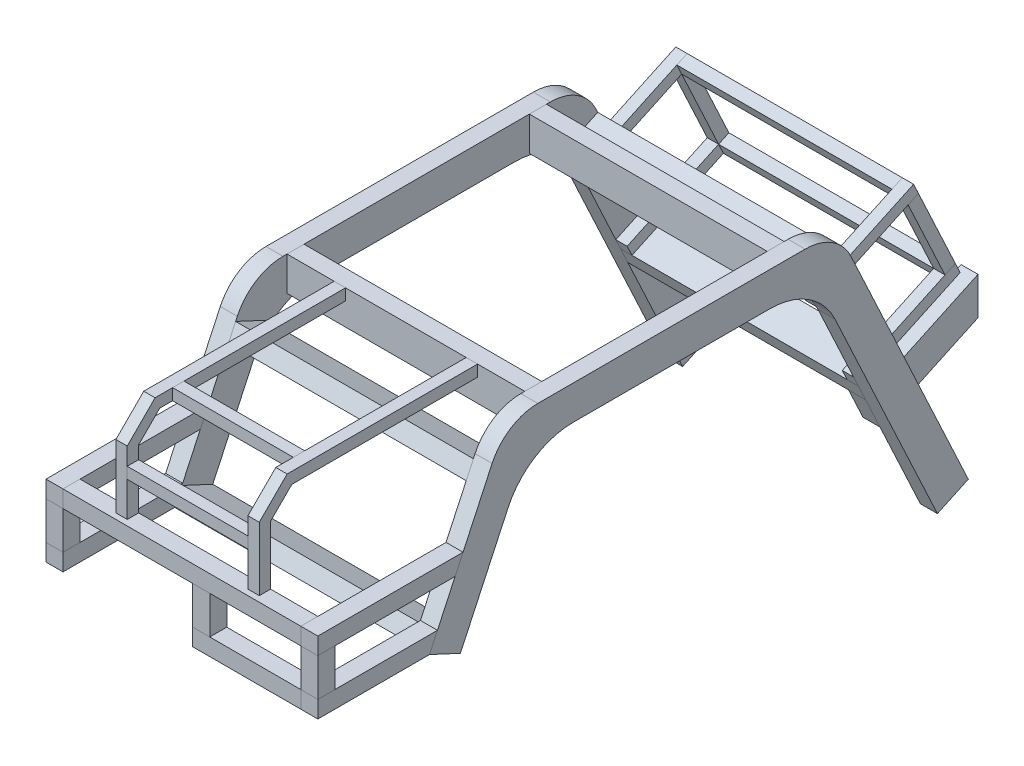
from build123d import *

# Parameters (mm, degrees)
BOSS_EXTRUDE1_START   = 239.55
BOSS_EXTRUDE1_DEPTH   = 30
BOSS_EXTRUDE2_DEPTH   = 30
BOSS_EXTRUDE2_2_DEPTH = 30
SKETCH12_W            = 29.999880001
SKETCH12_H            = 66.675
BOSS_EXTRUDE11_DEPTH  = 30
SKETCH3_W             = 30
SKETCH3_H             = 60
BOSS_EXTRUDE3_DEPTH   = 419.1
BOSS_EXTRUDE3_2_DEPTH = 419.1
BOSS_EXTRUDE3_3_DEPTH = 419.1
SKETCH3_W_2           = 29.999880001
SKETCH3_H_2           = 29.99988
BOSS_EXTRUDE3_4_DEPTH = 419.1
SKETCH3_H_3           = 29.999880001
BOSS_EXTRUDE3_5_DEPTH = 419.1
BOSS_EXTRUDE3_6_DEPTH = 419.1
BOSS_EXTRUDE3_7_DEPTH = 419.1
BOSS_EXTRUDE3_8_DEPTH = 419.1
BOSS_EXTRUDE4_DEPTH   = 30
BOSS_EXTRUDE5_DEPTH   = 30
BOSS_EXTRUDE5_2_DEPTH = 30
SKETCH13_W            = 29.999880001
SKETCH13_H            = 66.675
BOSS_EXTRUDE12_DEPTH  = 30
BOSS_EXTRUDE6_DEPTH   = 20
BOSS_EXTRUDE6_2_DEPTH = 20
BOSS_EXTRUDE13_DEPTH  = 20
BOSS_EXTRUDE7_DEPTH   = 379.1
BOSS_EXTRUDE7_2_DEPTH = 379.1
BOSS_EXTRUDE8_DEPTH   = 20
SKETCH9_W             = 20
SKETCH9_H             = 20
BOSS_EXTRUDE9_DEPTH   = 212.72
BOSS_EXTRUDE9_2_DEPTH = 212.72
SKETCH10_W            = 30
SKETCH10_H            = 66.675
BOSS_EXTRUDE10_DEPTH  = 30
SKETCH11_W            = 228.60006
SKETCH11_H            = 29.999880001
CUT_EXTRUDE1_DEPTH    = 29.99988
BOSS_EXTRUDE14_DEPTH  = 30
FILLET1_R             = 88.9
FILLET2_R             = 88.9
FILLET3_R             = 127
FILLET4_R             = 127


with BuildPart() as part:
    # Sketch1 → Boss-Extrude1 (new body)
    with BuildSketch(Plane(origin=(0, 0, 0), x_dir=(0, 0, -1), z_dir=(1, 0, 0)).offset(BOSS_EXTRUDE1_START)):
        Polygon((254, -30), (-254, -30), (-372.07954233, -283.222395698), (-426.458009553, -257.865299994), (-292.224215648, 30), (292.224215648, 30), (523.068544186, -465.04726011), (468.690076964, -490.404355815), align=None)
    extrude(amount=-BOSS_EXTRUDE1_DEPTH)

    # Fillet1
    fillet1_edges = [part.edges().sort_by_distance(p)[0] for p in [
        (224.55, 30, 292.224215648),
        (224.55, 30, -292.224215648),
    ]]
    fillet(fillet1_edges, radius=FILLET1_R)

    # Fillet3
    fillet3_edges = [part.edges().sort_by_distance(p)[0] for p in [
        (224.55, -30, -254),
        (224.55, -30, 254),
    ]]
    fillet(fillet3_edges, radius=FILLET3_R)


with BuildPart() as body_2:
    # Sketch2 → Boss-Extrude2 (new body)
    with BuildSketch(Plane(origin=(239.55, 0, 0), x_dir=(0, 0, -1), z_dir=(1, 0, 0))):
        Polygon((-381.377772657, -161.190419993), (-623.308009553, -161.190419993), (-623.308009553, -131.190539993), (-367.388598869, -131.190539993), align=None)
    extrude(amount=-BOSS_EXTRUDE2_DEPTH)


with BuildPart() as body_3:
    # Sketch2 → Boss-Extrude2 2 (new body)
    with BuildSketch(Plane(origin=(239.55, 0, 0), x_dir=(0, 0, -1), z_dir=(1, 0, 0))):
        Polygon((-412.468835765, -227.865419993), (-623.308009553, -227.865419993), (-623.308009553, -257.865299994), (-426.458009553, -257.865299994), align=None)
    extrude(amount=-BOSS_EXTRUDE2_2_DEPTH)


with BuildPart() as body_4:
    # Sketch12 → Boss-Extrude11 (new body)
    with BuildSketch(Plane(origin=(239.55, 0, 0), x_dir=(0, 0, -1), z_dir=(1, 0, 0))):
        with Locations((-608.308069553, -194.527919993)):
            Rectangle(SKETCH12_W, SKETCH12_H)
    extrude(amount=-BOSS_EXTRUDE11_DEPTH)


with BuildPart() as body_5:
    # Sketch3 → Boss-Extrude3 (new body)
    with BuildSketch(Plane.ZY.offset(-209.55)):
        with Locations((213.6, 0)):
            Rectangle(SKETCH3_W, SKETCH3_H)
    extrude(amount=BOSS_EXTRUDE3_DEPTH)


with BuildPart() as body_6:
    # Sketch3 → Boss-Extrude3 2 (new body)
    with BuildSketch(Plane.ZY.offset(-209.55)):
        Polygon((264.734503848, -53.020217791), (319.11297107, -27.663122086), (331.791518923, -54.852355697), (277.4130517, -80.209451402), align=None)
    extrude(amount=BOSS_EXTRUDE3_2_DEPTH)


with BuildPart() as body_7:
    # Sketch3 → Boss-Extrude3 3 (new body)
    with BuildSketch(Plane.ZY.offset(-209.55)):
        Polygon((372.07954233, -283.222395698), (426.458009553, -257.865299994), (413.7794617, -230.676066382), (359.400994478, -256.033162087), align=None)
    extrude(amount=BOSS_EXTRUDE3_3_DEPTH)


with BuildPart() as body_8:
    # Sketch3 → Boss-Extrude3 4 (new body)
    with BuildSketch(Plane.ZY.offset(-209.55)):
        with Locations((608.308069553, -146.190479993)):
            Rectangle(SKETCH3_W_2, SKETCH3_H_2)
    extrude(amount=BOSS_EXTRUDE3_4_DEPTH)


with BuildPart() as body_9:
    # Sketch3 → Boss-Extrude3 5 (new body)
    with BuildSketch(Plane.ZY.offset(-209.55)):
        with Locations((608.308069553, -242.865359994)):
            Rectangle(SKETCH3_W_2, SKETCH3_H_3)
    extrude(amount=BOSS_EXTRUDE3_5_DEPTH)

    # Sketch11 → Cut-Extrude1 (cut)
    with BuildSketch(Plane.XY.offset(623.308009553)):
        with Locations((-95.24997, -242.865359994)):
            Rectangle(SKETCH11_W, SKETCH11_H)
    extrude(amount=-CUT_EXTRUDE1_DEPTH, mode=Mode.SUBTRACT)


with BuildPart() as body_10:
    # Sketch3 → Boss-Extrude3 6 (new body)
    with BuildSketch(Plane.ZY.offset(-209.55)):
        Polygon((-359.400994478, -256.033162087), (-372.07954233, -283.222395698), (-426.458009553, -257.865299994), (-413.7794617, -230.676066382), align=None)
    extrude(amount=BOSS_EXTRUDE3_6_DEPTH)


with BuildPart() as body_11:
    # Sketch3 → Boss-Extrude3 7 (new body)
    with BuildSketch(Plane.ZY.offset(-209.55)):
        with Locations((-213.6, 0)):
            Rectangle(SKETCH3_W, SKETCH3_H)
    extrude(amount=BOSS_EXTRUDE3_7_DEPTH)


with BuildPart() as body_12:
    # Sketch3 → Boss-Extrude3 8 (new body)
    with BuildSketch(Plane.ZY.offset(-209.55)):
        Polygon((-331.791518923, -54.852355697), (-319.11297107, -27.663122086), (-264.734503848, -53.020217791), (-277.4130517, -80.209451402), align=None)
    extrude(amount=BOSS_EXTRUDE3_8_DEPTH)


with BuildPart() as body_13:
    # Sketch4 → Boss-Extrude4 (new body)
    with BuildSketch(Plane.ZY.offset(209.55)):
        Polygon((372.07954233, -283.222395698), (426.458009553, -257.865299994), (292.224215648, 30), (-292.224215648, 30), (-523.068544186, -465.04726011), (-468.690076964, -490.404355815), (-254, -30), (254, -30), align=None)
    extrude(amount=BOSS_EXTRUDE4_DEPTH)

    # Fillet2
    fillet2_edges = [body_13.edges().sort_by_distance(p)[0] for p in [
        (-224.55, 30, -292.224215648),
        (-224.55, 30, 292.224215648),
    ]]
    fillet(fillet2_edges, radius=FILLET2_R)

    # Fillet4
    fillet4_edges = [body_13.edges().sort_by_distance(p)[0] for p in [
        (-224.55, -30, 254),
        (-224.55, -30, -254),
    ]]
    fillet(fillet4_edges, radius=FILLET4_R)


with BuildPart() as body_14:
    # Sketch5 → Boss-Extrude5 (new body)
    with BuildSketch(Plane.ZY.offset(239.55)):
        Polygon((623.308009553, -227.865419993), (412.468835765, -227.865419993), (426.458009553, -257.865299994), (623.308009553, -257.865299994), align=None)
    extrude(amount=-BOSS_EXTRUDE5_DEPTH)


with BuildPart() as body_15:
    # Sketch5 → Boss-Extrude5 2 (new body)
    with BuildSketch(Plane.ZY.offset(239.55)):
        Polygon((381.377772657, -161.190419993), (623.308009553, -161.190419993), (623.308009553, -131.190539993), (367.388598869, -131.190539993), align=None)
    extrude(amount=-BOSS_EXTRUDE5_2_DEPTH)


with BuildPart() as body_16:
    # Sketch13 → Boss-Extrude12 (new body)
    with BuildSketch(Plane.ZY.offset(239.55)):
        with Locations((608.308069553, -194.527919993)):
            Rectangle(SKETCH13_W, SKETCH13_H)
    extrude(amount=-BOSS_EXTRUDE12_DEPTH)


with BuildPart() as body_17:
    # Sketch6 → Boss-Extrude6 (new body)
    with BuildSketch(Plane.ZY.offset(209.55)):
        Polygon((-456.680731976, 3.38444077), (-277.4130517, -80.209451402), (-285.865416935, -98.335607143), (-465.133097211, -14.74171497), align=None)
    extrude(amount=-BOSS_EXTRUDE6_DEPTH)


with BuildPart() as body_18:
    # Sketch6 → Boss-Extrude6 2 (new body)
    with BuildSketch(Plane.ZY.offset(209.55)):
        Polygon((-530.216309519, -154.313114174), (-350.948629243, -237.907006346), (-359.400994478, -256.033162087), (-538.668674754, -172.439269915), align=None)
    extrude(amount=-BOSS_EXTRUDE6_2_DEPTH)


with BuildPart() as body_19:
    # Sketch14 → Boss-Extrude13 (new body)
    with BuildSketch(Plane.ZY.offset(209.55)):
        Polygon((-465.133097211, -14.74171497), (-530.216309519, -154.313114174), (-512.090153778, -162.765479409), (-447.00694147, -23.194080205), align=None)
    extrude(amount=-BOSS_EXTRUDE13_DEPTH)


with BuildPart() as body_20:
    # Mirror1: mirrored copy
    add(body_18.part.mirror(Plane.ZY))


with BuildPart() as body_21:
    # Mirror1 2: mirrored copy
    add(body_17.part.mirror(Plane.ZY))


with BuildPart() as body_22:
    # Mirror1 3: mirrored copy
    add(body_19.part.mirror(Plane.ZY))


with BuildPart() as body_23:
    # Sketch7 → Boss-Extrude7 (new body)
    with BuildSketch(Plane.ZY.offset(-189.55)):
        Polygon((-447.00694147, -23.194080205), (-438.554576236, -5.067924464), (-456.680731976, 3.38444077), (-465.133097211, -14.74171497), align=None)
    extrude(amount=BOSS_EXTRUDE7_DEPTH)


with BuildPart() as body_24:
    # Sketch7 → Boss-Extrude7 2 (new body)
    with BuildSketch(Plane.ZY.offset(-189.55)):
        Polygon((-512.090153778, -162.765479409), (-520.542519013, -180.891635149), (-538.668674754, -172.439269915), (-530.216309519, -154.313114174), align=None)
    extrude(amount=BOSS_EXTRUDE7_2_DEPTH)


with BuildPart() as body_25:
    # Sketch8 → Boss-Extrude8 (new body)
    with BuildSketch(Plane.ZY.offset(126.36)):
        Polygon((613.308129552, -19.083317078), (613.308129552, -131.190539993), (593.308129552, -131.190539993), (593.308129552, -27.367588325), (555.940541227, 10), (228.6, 10), (228.6, 30), (564.224812475, 30), align=None)
    extrude(amount=-BOSS_EXTRUDE8_DEPTH)


with BuildPart() as body_26:
    # Mirror2: mirrored copy
    add(body_25.part.mirror(Plane.ZY))


with BuildPart() as body_27:
    # Sketch9 → Boss-Extrude9 (new body)
    with BuildSketch(Plane(origin=(-106.36, 0, 0), x_dir=(0, 0, -1), z_dir=(1, 0, 0))):
        with Locations((-523.310598912, 20)):
            Rectangle(SKETCH9_W, SKETCH9_H)
    extrude(amount=BOSS_EXTRUDE9_DEPTH)


with BuildPart() as body_28:
    # Sketch9 → Boss-Extrude9 2 (new body)
    with BuildSketch(Plane(origin=(-106.36, 0, 0), x_dir=(0, 0, -1), z_dir=(1, 0, 0))):
        with Locations((-603.308129552, -59.997474683)):
            Rectangle(SKETCH9_W, SKETCH9_H)
    extrude(amount=BOSS_EXTRUDE9_2_DEPTH)


with BuildPart() as body_29:
    # Sketch10 → Boss-Extrude10 (new body)
    with BuildSketch(Plane.XY.offset(623.308009553)):
        with Locations((34.05006, -194.527919993)):
            Rectangle(SKETCH10_W, SKETCH10_H)
    extrude(amount=-BOSS_EXTRUDE10_DEPTH)


with BuildPart() as body_30:
    # Sketch15 → Boss-Extrude14 (new body)
    with BuildSketch(Plane.ZY.offset(-209.55)):
        Polygon((-397.436638035, -337.60086292), (-570.184995851, -257.046980737), (-570.184995851, -190.844305599), (-372.07954233, -283.222395698), align=None)
    extrude(amount=BOSS_EXTRUDE14_DEPTH)


solid = Compound([part.part, body_2.part, body_3.part, body_4.part, body_5.part, body_6.part, body_7.part, body_8.part, body_9.part, body_10.part, body_11.part, body_12.part, body_13.part, body_14.part, body_15.part, body_16.part, body_17.part, body_18.part, body_19.part, body_20.part, body_21.part, body_22.part, body_23.part, body_24.part, body_25.part, body_26.part, body_27.part, body_28.part, body_29.part, body_30.part])
